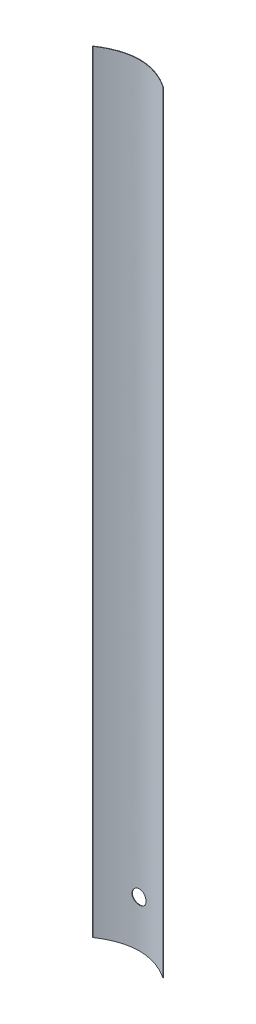
from build123d import *

# Parameters (mm, degrees)
BOSS_EXTRUDE1_DEPTH = 165.1
SKETCH2_R           = 1.5
CUT_EXTRUDE1_DEPTH  = 3.5500001


with BuildPart() as part:
    # Sketch1 → Boss-Extrude1 (new body)
    with BuildSketch(Plane(origin=(0, 0, 0), x_dir=(1, 0, 0), z_dir=(0, 1, 0))):
        with BuildLine():
            Line((7.55, -2.55), (7.45, -2.55))
            add(Edge.make_bspline(
                [(-7.45, -2.55), (0, 2.35), (7.45, -2.55)],
                knots=[0, 0, 0, 1, 1, 1], degree=2))
            Line((-7.45, -2.55), (-7.55, -2.55))
            add(Edge.make_bspline(
                [(7.55, -2.55), (0, 2.55), (-7.55, -2.55)],
                knots=[0, 0, 0, 1, 1, 1], degree=2))
        make_face()
    extrude(amount=BOSS_EXTRUDE1_DEPTH)

    # Sketch2 → Cut-Extrude1 (cut, through all)
    with BuildSketch(Plane.XY):
        with Locations((0, 10)):
            Circle(SKETCH2_R)
    extrude(amount=CUT_EXTRUDE1_DEPTH, mode=Mode.SUBTRACT)


solid = part.part
